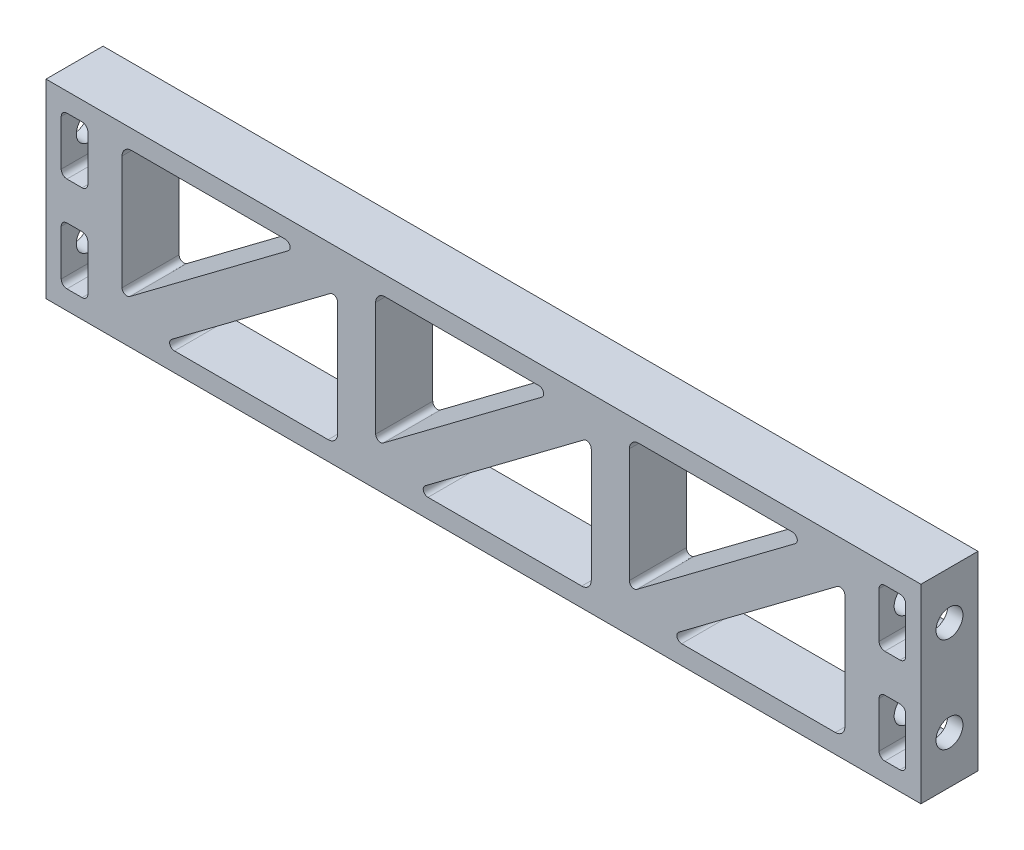
from build123d import *

# Parameters (mm, degrees)
SKETCH2_W                                  = 146.05
SKETCH2_H                                  = 31.75
BOSS_EXTRUDE2_DEPTH                        = 9.525
SKETCH3_R                                  = 2.2479
CUT_EXTRUDE1_DEPTH                         = 11.1125
MIRROR1_AT_THE_SECOND_PLANE_COPY_1_SKETC_R = 2.2479
MIRROR1_AT_THE_SECOND_PLANE_COPY_1_DEPTH   = 11.1125


with BuildPart() as part:
    # Sketch2 → Boss-Extrude2 (new body)
    with BuildSketch(Plane.XY):
        Rectangle(SKETCH2_W, SKETCH2_H)
        with BuildLine():
            Line((-58.7375, 12.7), (-33.072916667, 12.7))
            ThreePointArc((-33.072916667, 12.7), (-32.319899299, 12.157255789), (-32.596666667, 11.27125))
            Line((-32.596666667, 11.27125), (-59.055, -8.5725))
            ThreePointArc((-59.055, -8.5725), (-59.886225791, -8.647451583), (-60.325, -7.9375))
            Line((-60.325, -7.9375), (-60.325, 11.1125))
            ThreePointArc((-60.325, 11.1125), (-59.860032015, 12.235032015), (-58.7375, 12.7))
        make_face(mode=Mode.SUBTRACT)
        with BuildLine():
            Line((-51.59375, -12.7), (-25.929166667, -12.7))
            ThreePointArc((-25.929166667, -12.7), (-24.806634652, -12.235032015), (-24.341666667, -11.1125))
            Line((-24.341666667, -11.1125), (-24.341666667, 7.9375))
            ThreePointArc((-24.341666667, 7.9375), (-24.780440875, 8.647451583), (-25.611666667, 8.5725))
            Line((-25.611666667, 8.5725), (-52.07, -11.27125))
            ThreePointArc((-52.07, -11.27125), (-52.346767368, -12.157255789), (-51.59375, -12.7))
        make_face(mode=Mode.SUBTRACT)
        with BuildLine():
            Line((17.991666667, -11.1125), (17.991666667, 7.9375))
            ThreePointArc((17.991666667, 7.9375), (17.552892458, 8.647451583), (16.721666667, 8.5725))
            Line((16.721666667, 8.5725), (-9.736666667, -11.27125))
            ThreePointArc((-9.736666667, -11.27125), (-10.013434034, -12.157255789), (-9.260416667, -12.7))
            Line((-9.260416667, -12.7), (16.404166667, -12.7))
            ThreePointArc((16.404166667, -12.7), (17.526698682, -12.235032015), (17.991666667, -11.1125))
        make_face(mode=Mode.SUBTRACT)
        with BuildLine():
            Line((-16.721666667, -8.5725), (9.736666667, 11.27125))
            ThreePointArc((9.736666667, 11.27125), (10.013434034, 12.157255789), (9.260416667, 12.7))
            Line((9.260416667, 12.7), (-16.404166667, 12.7))
            ThreePointArc((-16.404166667, 12.7), (-17.526698682, 12.235032015), (-17.991666667, 11.1125))
            Line((-17.991666667, 11.1125), (-17.991666667, -7.9375))
            ThreePointArc((-17.991666667, -7.9375), (-17.552892458, -8.647451583), (-16.721666667, -8.5725))
        make_face(mode=Mode.SUBTRACT)
        with BuildLine():
            Line((60.325, -11.1125), (60.325, 7.9375))
            ThreePointArc((60.325, 7.9375), (59.886225791, 8.647451583), (59.055, 8.5725))
            Line((59.055, 8.5725), (32.596666667, -11.27125))
            ThreePointArc((32.596666667, -11.27125), (32.319899299, -12.157255789), (33.072916667, -12.7))
            Line((33.072916667, -12.7), (58.7375, -12.7))
            ThreePointArc((58.7375, -12.7), (59.860032015, -12.235032015), (60.325, -11.1125))
        make_face(mode=Mode.SUBTRACT)
        with BuildLine():
            Line((25.611666667, -8.5725), (52.07, 11.27125))
            ThreePointArc((52.07, 11.27125), (52.346767368, 12.157255789), (51.59375, 12.7))
            Line((51.59375, 12.7), (25.929166667, 12.7))
            ThreePointArc((25.929166667, 12.7), (24.806634652, 12.235032015), (24.341666667, 11.1125))
            Line((24.341666667, 11.1125), (24.341666667, -7.9375))
            ThreePointArc((24.341666667, -7.9375), (24.780440875, -8.647451583), (25.611666667, -8.5725))
        make_face(mode=Mode.SUBTRACT)
        with BuildLine():
            Line((-69.5325, 12.7), (-66.9925, 12.7))
            ThreePointArc((-66.9925, 12.7), (-66.318980791, 12.421019209), (-66.04, 11.7475))
            Line((-66.04, 11.7475), (-66.04, 4.1275))
            ThreePointArc((-66.04, 4.1275), (-66.318980791, 3.453980791), (-66.9925, 3.175))
            Line((-66.9925, 3.175), (-69.5325, 3.175))
            ThreePointArc((-69.5325, 3.175), (-70.206019209, 3.453980791), (-70.485, 4.1275))
            Line((-70.485, 4.1275), (-70.485, 11.7475))
            ThreePointArc((-70.485, 11.7475), (-70.206019209, 12.421019209), (-69.5325, 12.7))
        make_face(mode=Mode.SUBTRACT)
        with BuildLine():
            Line((-66.04, -11.7475), (-66.04, -4.1275))
            ThreePointArc((-66.04, -4.1275), (-66.318980791, -3.453980791), (-66.9925, -3.175))
            Line((-66.9925, -3.175), (-69.5325, -3.175))
            ThreePointArc((-69.5325, -3.175), (-70.206019209, -3.453980791), (-70.485, -4.1275))
            Line((-70.485, -4.1275), (-70.485, -11.7475))
            ThreePointArc((-70.485, -11.7475), (-70.206019209, -12.421019209), (-69.5325, -12.7))
            Line((-69.5325, -12.7), (-66.9925, -12.7))
            ThreePointArc((-66.9925, -12.7), (-66.318980791, -12.421019209), (-66.04, -11.7475))
        make_face(mode=Mode.SUBTRACT)
        with BuildLine():
            Line((69.5325, -12.7), (66.9925, -12.7))
            ThreePointArc((66.9925, -12.7), (66.318980791, -12.421019209), (66.04, -11.7475))
            Line((66.04, -11.7475), (66.04, -4.1275))
            ThreePointArc((66.04, -4.1275), (66.318980791, -3.453980791), (66.9925, -3.175))
            Line((66.9925, -3.175), (69.5325, -3.175))
            ThreePointArc((69.5325, -3.175), (70.206019209, -3.453980791), (70.485, -4.1275))
            Line((70.485, -4.1275), (70.485, -11.7475))
            ThreePointArc((70.485, -11.7475), (70.206019209, -12.421019209), (69.5325, -12.7))
        make_face(mode=Mode.SUBTRACT)
        with BuildLine():
            Line((66.04, 11.7475), (66.04, 4.1275))
            ThreePointArc((66.04, 4.1275), (66.318980791, 3.453980791), (66.9925, 3.175))
            Line((66.9925, 3.175), (69.5325, 3.175))
            ThreePointArc((69.5325, 3.175), (70.206019209, 3.453980791), (70.485, 4.1275))
            Line((70.485, 4.1275), (70.485, 11.7475))
            ThreePointArc((70.485, 11.7475), (70.206019209, 12.421019209), (69.5325, 12.7))
            Line((69.5325, 12.7), (66.9925, 12.7))
            ThreePointArc((66.9925, 12.7), (66.318980791, 12.421019209), (66.04, 11.7475))
        make_face(mode=Mode.SUBTRACT)
    extrude(amount=BOSS_EXTRUDE2_DEPTH)

    # Sketch3 → Cut-Extrude1 (cut)
    with BuildSketch(Plane.ZY.offset(73.025)):
        with Locations((4.7625, 7.9375)):
            Circle(SKETCH3_R)
    cut_extrude1 = extrude(amount=-CUT_EXTRUDE1_DEPTH, mode=Mode.SUBTRACT)

    # Mirror1: Cut-Extrude1 across plane
    add(cut_extrude1.mirror(Plane(origin=(0, 0, 0), x_dir=(0, 0, 1), z_dir=(1, 0, 0))), mode=Mode.SUBTRACT)

    # Mirror1 at the second plane: Cut-Extrude1 across plane
    add(cut_extrude1.mirror(Plane.ZX), mode=Mode.SUBTRACT)

    # Mirror1 at the second plane copy 1 sketc → Mirror1 at the second plane copy 1 (cut)
    with BuildSketch(Plane(origin=(73.025, 0, 0), x_dir=(0, 0, 1), z_dir=(1, 0, 0))):
        with Locations((4.7625, 7.9375)):
            Circle(MIRROR1_AT_THE_SECOND_PLANE_COPY_1_SKETC_R)
    extrude(amount=-MIRROR1_AT_THE_SECOND_PLANE_COPY_1_DEPTH, mode=Mode.SUBTRACT)


solid = part.part
